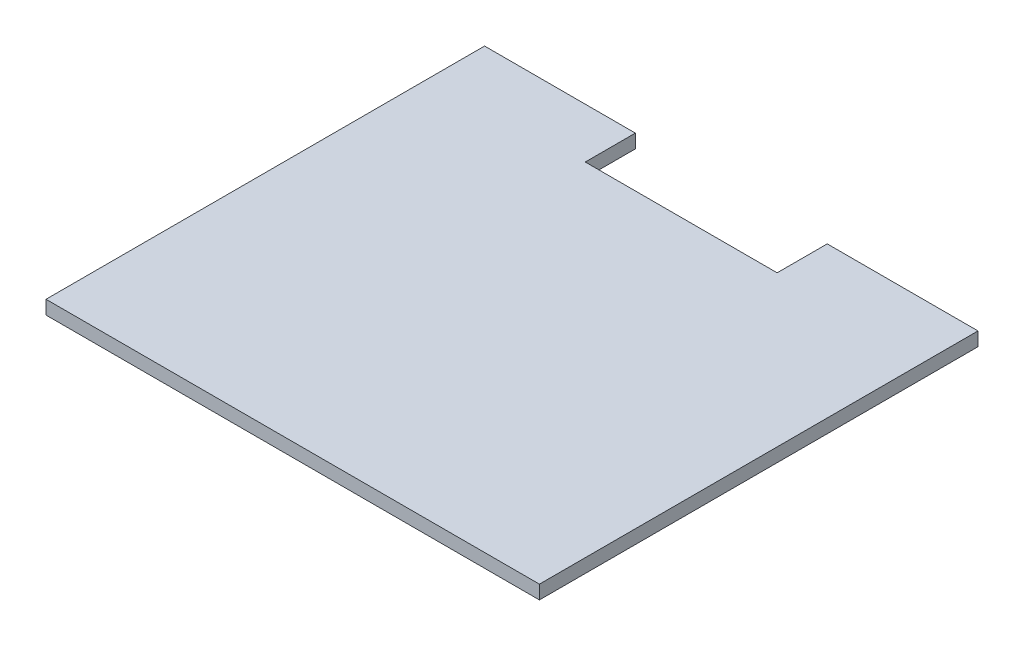
from build123d import *

# Parameters (mm, degrees)
BOSS_EXTRUDE1_DEPTH = 5


with BuildPart() as part:
    # Sketch1 → Boss-Extrude1 (new body)
    with BuildSketch(Plane(origin=(0, 0, 0), x_dir=(1, 0, 0), z_dir=(0, 1, 0))):
        Polygon((-154.246153846, 70.830769231), (-154.246153846, -89.169230769), (25.753846154, -89.169230769), (25.753846154, 70.830769231), (-29.246153846, 70.830769231), (-29.246153846, 52.553846154), (-99.246153846, 52.553846154), (-99.246153846, 70.830769231), align=None)
    extrude(amount=BOSS_EXTRUDE1_DEPTH)


solid = part.part
